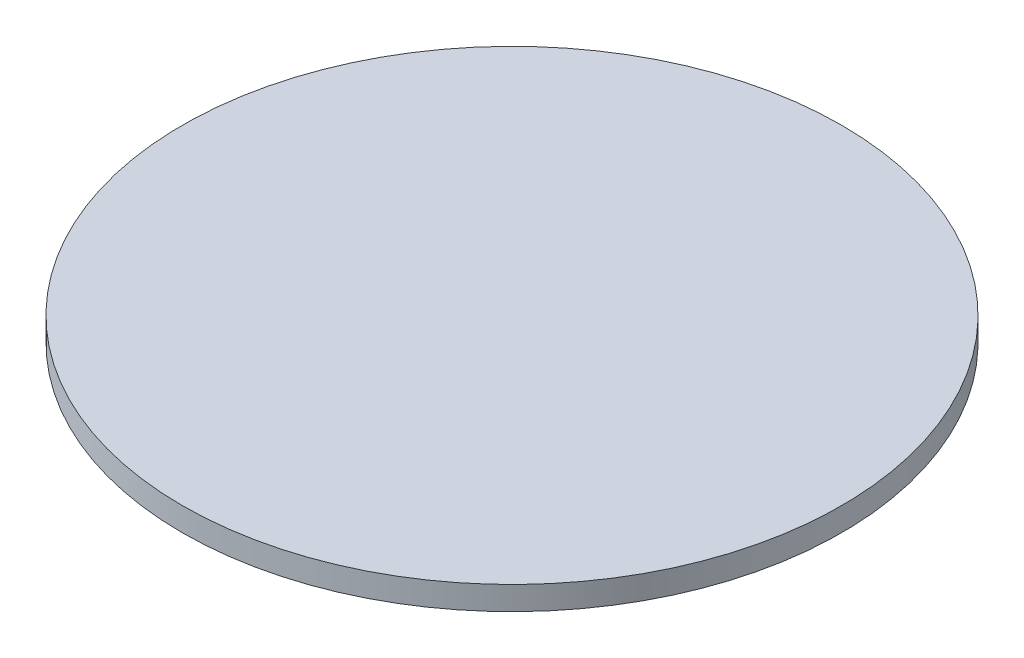
from build123d import *

# Parameters (mm, degrees)
SKETCH1_R           = 1400
BOSS_EXTRUDE1_DEPTH = 100


with BuildPart() as part:
    # Sketch1 → Boss-Extrude1 (new body)
    with BuildSketch(Plane(origin=(0, 0, 0), x_dir=(1, 0, 0), z_dir=(0, 1, 0))):
        Circle(SKETCH1_R)
    extrude(amount=BOSS_EXTRUDE1_DEPTH)


solid = part.part
